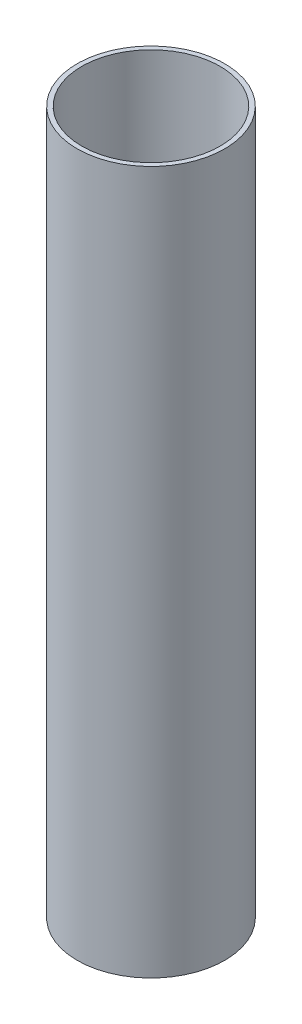
from build123d import *

# Parameters (mm, degrees)
SKETCH1_R           = 40
SKETCH1_R_2         = 37.5
BOSS_EXTRUDE1_DEPTH = 381


with BuildPart() as part:
    # Sketch1 → Boss-Extrude1 (new body)
    with BuildSketch(Plane(origin=(0, 0, 0), x_dir=(1, 0, 0), z_dir=(0, 1, 0))):
        Circle(SKETCH1_R)
        Circle(SKETCH1_R_2, mode=Mode.SUBTRACT)
    extrude(amount=BOSS_EXTRUDE1_DEPTH)


solid = part.part
